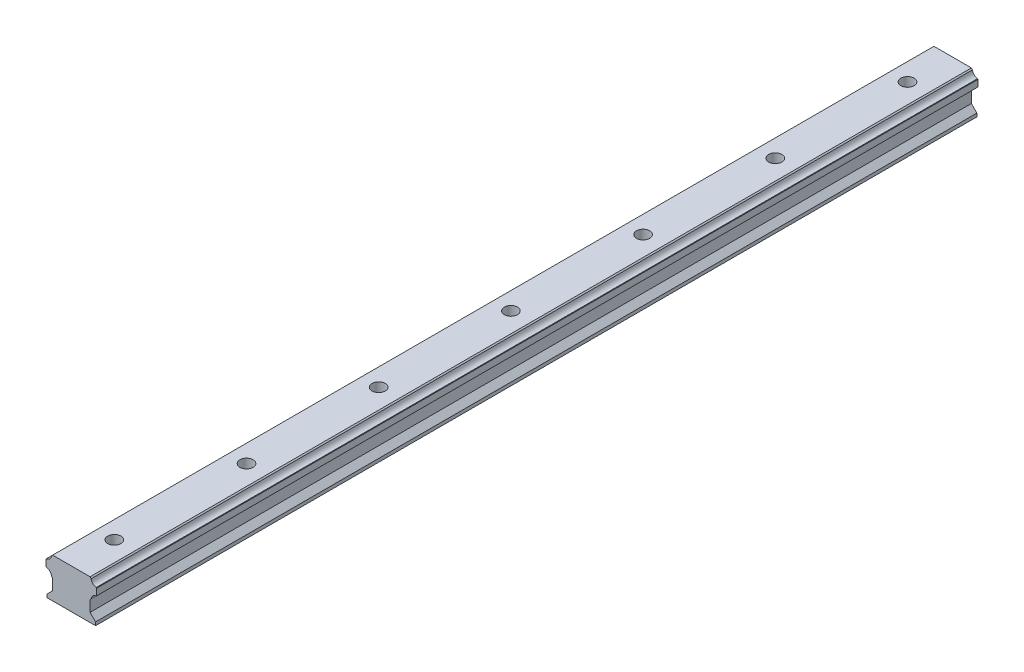
from build123d import *

# Parameters (mm, degrees)
ESTRUSIONE_ESTRUSIONE1_DEPTH      = 400
SCHIZZO2_R                        = 3
TAGLIO_ESTRUSIONE1_DEPTH          = 19
RIPETIZIONE_A_L1_COUNT            = 4
RIPETIZIONE_A_L1_PITCH            = 60
RIPETIZIONE_A_L2_COPY_1_SKETCH_R  = 3
RIPETIZIONE_A_L2_COPY_1_DEPTH     = 19
RIPETIZIONE_A_L2_COPY_2_SKETCH_R  = 3
RIPETIZIONE_A_L2_COPY_2_DEPTH     = 19
RIPETIZIONE_A_L2_COPY_3_SKETCH_R  = 3
RIPETIZIONE_A_L2_COPY_3_DEPTH     = 19
RIPETIZIONE_A_L2_COPY_4_SKETCH_R  = 3
RIPETIZIONE_A_L2_COPY_4_DEPTH     = 19
RIPETIZIONE_A_L2_COPY_5_SKETCH_R  = 3
RIPETIZIONE_A_L2_COPY_5_DEPTH     = 19
RIPETIZIONE_A_L2_COPY_6_SKETCH_R  = 3
RIPETIZIONE_A_L2_COPY_6_DEPTH     = 19
RIPETIZIONE_A_L2_COPY_7_SKETCH_R  = 3
RIPETIZIONE_A_L2_COPY_7_DEPTH     = 19
RIPETIZIONE_A_L2_COPY_8_SKETCH_R  = 3
RIPETIZIONE_A_L2_COPY_8_DEPTH     = 19
RIPETIZIONE_A_L2_COPY_9_SKETCH_R  = 3
RIPETIZIONE_A_L2_COPY_9_DEPTH     = 19
RIPETIZIONE_A_L2_COPY_10_SKETCH_R = 3
RIPETIZIONE_A_L2_COPY_10_DEPTH    = 19
RIPETIZIONE_A_L2_COPY_11_SKETCH_R = 3
RIPETIZIONE_A_L2_COPY_11_DEPTH    = 19
RIPETIZIONE_A_L2_COPY_12_SKETCH_R = 3
RIPETIZIONE_A_L2_COPY_12_DEPTH    = 19


with BuildPart() as part:
    # Schizzo1 → Estrusione-Estrusione1 (new body)
    with BuildSketch(Plane.XY):
        with BuildLine():
            Line((-10.001211602, -16.276222172), (-7.501211602, -13.776222172))
            Line((-7.501211602, -13.776222172), (-7.501211602, -8.776222172))
            Line((-7.501211602, -8.776222172), (-8.008796188, -8.268637585))
            ThreePointArc((-8.008796188, -8.268637585), (-8.733444649, -6.695460987), (-10.306621247, -5.970812526))
            Line((-10.306621247, -5.970812526), (-10.501211602, -5.776222172))
            Line((-10.501211602, -5.776222172), (-10.501211602, -2.776222172))
            Line((-10.501211602, -2.776222172), (-10.306621247, -2.581631817))
            ThreePointArc((-10.306621247, -2.581631817), (-8.733444649, -1.856983356), (-8.008796188, -0.283806758))
            Line((-8.008796188, -0.283806758), (-7.501211602, 0.223777828))
            Line((-7.501211602, 0.223777828), (9.498788398, 0.223777828))
            Line((9.498788398, 0.223777828), (10.006372984, -0.283806758))
            ThreePointArc((10.006372984, -0.283806758), (10.731021445, -1.856983356), (12.304198043, -2.581631817))
            Line((12.304198043, -2.581631817), (12.498788398, -2.776222172))
            Line((12.498788398, -2.776222172), (12.498788398, -5.776222172))
            Line((12.498788398, -5.776222172), (12.304198043, -5.970812526))
            ThreePointArc((12.304198043, -5.970812526), (10.731021445, -6.695460987), (10.006372984, -8.268637585))
            Line((10.006372984, -8.268637585), (9.498788398, -8.776222172))
            Line((9.498788398, -8.776222172), (9.498788398, -13.776222172))
            Line((9.498788398, -13.776222172), (11.998788398, -16.276222172))
            Line((11.998788398, -16.276222172), (11.998788398, -17.776222172))
            Line((11.998788398, -17.776222172), (-10.001211602, -17.776222172))
            Line((-10.001211602, -17.776222172), (-10.001211602, -16.276222172))
        make_face()
    extrude(amount=ESTRUSIONE_ESTRUSIONE1_DEPTH)

    # Schizzo2 → Taglio-Estrusione1 (cut, through all)
    with BuildSketch(Plane(origin=(0, 0.223777828, 0), x_dir=(1, 0, 0), z_dir=(0, 1, 0))):
        with Locations((0.499394199, -200)):
            Circle(SCHIZZO2_R)
    taglio_estrusione1 = extrude(amount=-TAGLIO_ESTRUSIONE1_DEPTH, mode=Mode.SUBTRACT)

    # Ripetizione a L1: Taglio-Estrusione1 ×4
    with Locations(*[(0, 0, i * RIPETIZIONE_A_L1_PITCH) for i in range(1, RIPETIZIONE_A_L1_COUNT)]):
        add(taglio_estrusione1, mode=Mode.SUBTRACT)

    # Ripetizione a L2 copy 1 sketch → Ripetizione a L2 copy 1 (cut, through all)
    with BuildSketch(Plane(origin=(0, 0.223777828, 0), x_dir=(1, 0, 0), z_dir=(0, 1, 0))):
        with Locations((0.499394199, -200)):
            Circle(RIPETIZIONE_A_L2_COPY_1_SKETCH_R)
    extrude(amount=-RIPETIZIONE_A_L2_COPY_1_DEPTH, mode=Mode.SUBTRACT)

    # Ripetizione a L2 copy 2 sketch → Ripetizione a L2 copy 2 (cut, through all)
    with BuildSketch(Plane(origin=(0, 0.223777828, -60), x_dir=(1, 0, 0), z_dir=(0, 1, 0))):
        with Locations((0.499394199, -200)):
            Circle(RIPETIZIONE_A_L2_COPY_2_SKETCH_R)
    extrude(amount=-RIPETIZIONE_A_L2_COPY_2_DEPTH, mode=Mode.SUBTRACT)

    # Ripetizione a L2 copy 3 sketch → Ripetizione a L2 copy 3 (cut, through all)
    with BuildSketch(Plane(origin=(0, 0.223777828, -120), x_dir=(1, 0, 0), z_dir=(0, 1, 0))):
        with Locations((0.499394199, -200)):
            Circle(RIPETIZIONE_A_L2_COPY_3_SKETCH_R)
    extrude(amount=-RIPETIZIONE_A_L2_COPY_3_DEPTH, mode=Mode.SUBTRACT)

    # Ripetizione a L2 copy 4 sketch → Ripetizione a L2 copy 4 (cut, through all)
    with BuildSketch(Plane(origin=(0, 0.223777828, 60), x_dir=(1, 0, 0), z_dir=(0, 1, 0))):
        with Locations((0.499394199, -200)):
            Circle(RIPETIZIONE_A_L2_COPY_4_SKETCH_R)
    extrude(amount=-RIPETIZIONE_A_L2_COPY_4_DEPTH, mode=Mode.SUBTRACT)

    # Ripetizione a L2 copy 5 sketch → Ripetizione a L2 copy 5 (cut, through all)
    with BuildSketch(Plane(origin=(0, 0.223777828, 0), x_dir=(1, 0, 0), z_dir=(0, 1, 0))):
        with Locations((0.499394199, -200)):
            Circle(RIPETIZIONE_A_L2_COPY_5_SKETCH_R)
    extrude(amount=-RIPETIZIONE_A_L2_COPY_5_DEPTH, mode=Mode.SUBTRACT)

    # Ripetizione a L2 copy 6 sketch → Ripetizione a L2 copy 6 (cut, through all)
    with BuildSketch(Plane(origin=(0, 0.223777828, -60), x_dir=(1, 0, 0), z_dir=(0, 1, 0))):
        with Locations((0.499394199, -200)):
            Circle(RIPETIZIONE_A_L2_COPY_6_SKETCH_R)
    extrude(amount=-RIPETIZIONE_A_L2_COPY_6_DEPTH, mode=Mode.SUBTRACT)

    # Ripetizione a L2 copy 7 sketch → Ripetizione a L2 copy 7 (cut, through all)
    with BuildSketch(Plane(origin=(0, 0.223777828, 120), x_dir=(1, 0, 0), z_dir=(0, 1, 0))):
        with Locations((0.499394199, -200)):
            Circle(RIPETIZIONE_A_L2_COPY_7_SKETCH_R)
    extrude(amount=-RIPETIZIONE_A_L2_COPY_7_DEPTH, mode=Mode.SUBTRACT)

    # Ripetizione a L2 copy 8 sketch → Ripetizione a L2 copy 8 (cut, through all)
    with BuildSketch(Plane(origin=(0, 0.223777828, 60), x_dir=(1, 0, 0), z_dir=(0, 1, 0))):
        with Locations((0.499394199, -200)):
            Circle(RIPETIZIONE_A_L2_COPY_8_SKETCH_R)
    extrude(amount=-RIPETIZIONE_A_L2_COPY_8_DEPTH, mode=Mode.SUBTRACT)

    # Ripetizione a L2 copy 9 sketch → Ripetizione a L2 copy 9 (cut, through all)
    with BuildSketch(Plane(origin=(0, 0.223777828, 0), x_dir=(1, 0, 0), z_dir=(0, 1, 0))):
        with Locations((0.499394199, -200)):
            Circle(RIPETIZIONE_A_L2_COPY_9_SKETCH_R)
    extrude(amount=-RIPETIZIONE_A_L2_COPY_9_DEPTH, mode=Mode.SUBTRACT)

    # Ripetizione a L2 copy 10 sketch → Ripetizione a L2 copy 10 (cut, through all)
    with BuildSketch(Plane(origin=(0, 0.223777828, -60), x_dir=(1, 0, 0), z_dir=(0, 1, 0))):
        with Locations((0.499394199, -200)):
            Circle(RIPETIZIONE_A_L2_COPY_10_SKETCH_R)
    extrude(amount=-RIPETIZIONE_A_L2_COPY_10_DEPTH, mode=Mode.SUBTRACT)

    # Ripetizione a L2 copy 11 sketch → Ripetizione a L2 copy 11 (cut, through all)
    with BuildSketch(Plane(origin=(0, 0.223777828, -120), x_dir=(1, 0, 0), z_dir=(0, 1, 0))):
        with Locations((0.499394199, -200)):
            Circle(RIPETIZIONE_A_L2_COPY_11_SKETCH_R)
    extrude(amount=-RIPETIZIONE_A_L2_COPY_11_DEPTH, mode=Mode.SUBTRACT)

    # Ripetizione a L2 copy 12 sketch → Ripetizione a L2 copy 12 (cut, through all)
    with BuildSketch(Plane(origin=(0, 0.223777828, -180), x_dir=(1, 0, 0), z_dir=(0, 1, 0))):
        with Locations((0.499394199, -200)):
            Circle(RIPETIZIONE_A_L2_COPY_12_SKETCH_R)
    extrude(amount=-RIPETIZIONE_A_L2_COPY_12_DEPTH, mode=Mode.SUBTRACT)


solid = part.part
